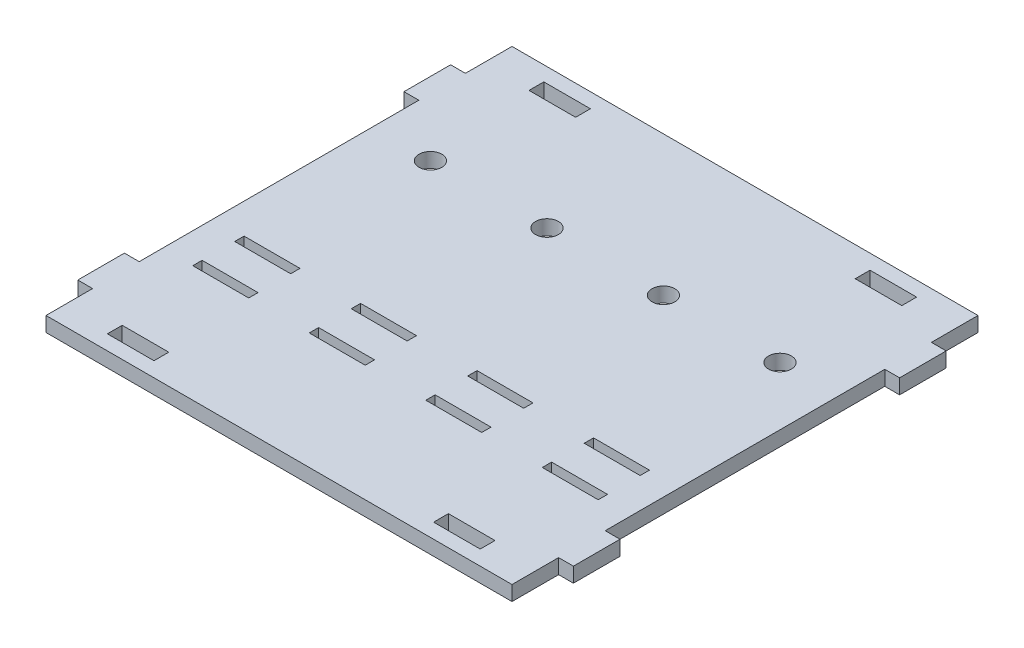
from build123d import *

# Parameters (mm, degrees)
SKETCH1_R           = 2.45
SKETCH1_W           = 10
SKETCH1_H           = 3.175
SKETCH1_W_2         = 12
SKETCH1_H_2         = 2
BOSS_EXTRUDE1_DEPTH = 3.175


with BuildPart() as part:
    # Sketch1 → Boss-Extrude1 (new body)
    with BuildSketch(Plane(origin=(0, 0, 0), x_dir=(1, 0, 0), z_dir=(0, 1, 0))):
        Polygon((0, 0), (100, 0), (100, 10), (103.175, 10), (103.175, 20), (100, 20), (100, 80), (103.175, 80), (103.175, 90), (100, 90), (100, 100), (0, 100), (0, 90), (-3.175, 90), (-3.175, 80), (0, 80), (0, 20), (-3.175, 20), (-3.175, 10), (0, 10), align=None)
        with Locations((12.5, 70)):
            Circle(SKETCH1_R, mode=Mode.SUBTRACT)
        with Locations((37.5, 70)):
            Circle(SKETCH1_R, mode=Mode.SUBTRACT)
        with Locations((62.5, 70)):
            Circle(SKETCH1_R, mode=Mode.SUBTRACT)
        with Locations((87.5, 70)):
            Circle(SKETCH1_R, mode=Mode.SUBTRACT)
        with Locations((15, 95.2375)):
            Rectangle(SKETCH1_W, SKETCH1_H, mode=Mode.SUBTRACT)
        with Locations((85, 95.2375)):
            Rectangle(SKETCH1_W, SKETCH1_H, mode=Mode.SUBTRACT)
        with Locations((85, 4.7625)):
            Rectangle(SKETCH1_W, SKETCH1_H, mode=Mode.SUBTRACT)
        with Locations((15, 4.7625)):
            Rectangle(SKETCH1_W, SKETCH1_H, mode=Mode.SUBTRACT)
        with Locations((37.5, 35)):
            Rectangle(SKETCH1_W_2, SKETCH1_H_2, mode=Mode.SUBTRACT)
        with Locations((12.5, 35)):
            Rectangle(SKETCH1_W_2, SKETCH1_H_2, mode=Mode.SUBTRACT)
        with Locations((12.5, 26)):
            Rectangle(SKETCH1_W_2, SKETCH1_H_2, mode=Mode.SUBTRACT)
        with Locations((37.5, 26)):
            Rectangle(SKETCH1_W_2, SKETCH1_H_2, mode=Mode.SUBTRACT)
        with Locations((62.5, 35)):
            Rectangle(SKETCH1_W_2, SKETCH1_H_2, mode=Mode.SUBTRACT)
        with Locations((62.5, 26)):
            Rectangle(SKETCH1_W_2, SKETCH1_H_2, mode=Mode.SUBTRACT)
        with Locations((87.5, 35)):
            Rectangle(SKETCH1_W_2, SKETCH1_H_2, mode=Mode.SUBTRACT)
        with Locations((87.5, 26)):
            Rectangle(SKETCH1_W_2, SKETCH1_H_2, mode=Mode.SUBTRACT)
    extrude(amount=BOSS_EXTRUDE1_DEPTH)


solid = part.part
